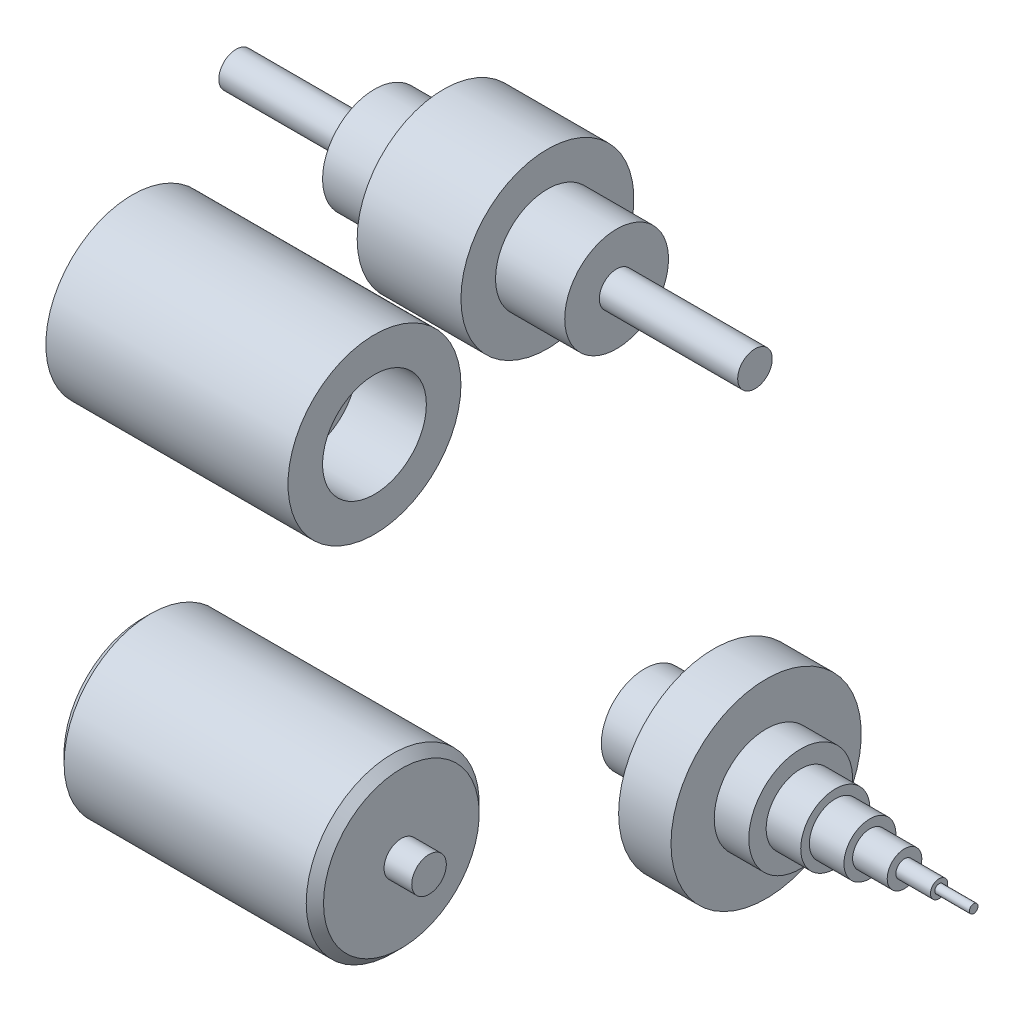
from build123d import *

# Parameters (mm, degrees)
CROQUIS5_R            = 20
CORTAR_EXTRUIR1_DEPTH = 43
CHAFL_N1_SIZE         = 5
CHAFL_N2_SIZE         = 5


with BuildPart() as part:
    # Croquis2 → Revoluci_n2 (revolve)
    with BuildSketch(Plane.XY):
        Polygon((-16.117690813, -67.997629677), (283.882309187, -67.997629677), (283.882309187, -57.997629677), (203.882309187, -57.997629677), (203.882309187, -37.997629677), (163.882309187, -37.997629677), (163.882309187, -17.997629677), (103.882309187, -17.997629677), (103.882309187, -37.997629677), (63.882309187, -37.997629677), (63.882309187, -57.997629677), (-16.117690813, -57.997629677), align=None)
    revolve(axis=Axis((-83.796377596, -67.997629677, 0), (1, 0, 0)))


with BuildPart() as body_2:
    # Croquis2_13 → Revoluci_n4 (revolve)
    with BuildSketch(Plane.XY):
        Polygon((-56.117690813, -220.867194058), (-56.117690813, -210.867194058), (-76.117690813, -210.867194058), (-76.117690813, -260.867194058), (63.882309187, -260.867194058), (63.882309187, -240.867194058), (23.882309187, -240.867194058), (23.882309187, -220.867194058), align=None)
    revolve(axis=Axis((101.470830931, -210.867194058, 0), (-1, 0, 0)))


with BuildPart() as body_3:
    # Croquis3 → Revoluci_n5 (revolve)
    with BuildSketch(Plane.XY):
        Polygon((410.329396223, -275.079193053), (410.329396223, -277.579193053), (390.329396223, -277.579193053), (390.329396223, -280.079193053), (370.329396223, -280.079193053), (370.329396223, -285.079193053), (350.329396223, -285.079193053), (350.329396223, -290.079193053), (330.329396223, -290.079193053), (330.329396223, -295.079193053), (310.329396223, -295.079193053), (310.329396223, -305.079193053), (290.329396223, -305.079193053), (290.329396223, -330.079193053), (260.048278244, -330.079193053), (260.048278244, -300.079193053), (220.048278244, -300.079193053), (220.048278244, -275.079193053), align=None)
    revolve(axis=Axis((141.076094876, -275.079193053, 0), (1, 0, 0)))

    # Croquis5 → Cortar-Extruir1 (cut)
    with BuildSketch(Plane.ZY.offset(-220.048278244)):
        with Locations((0, -275.079193053)):
            Circle(CROQUIS5_R)
    extrude(amount=-CORTAR_EXTRUIR1_DEPTH, mode=Mode.SUBTRACT)


with BuildPart() as body_4:
    # Croquis6 → Revoluci_n6 (revolve)
    with BuildSketch(Plane.XY):
        Polygon((-86.571698606, -415.362975234), (-86.571698606, -405.362975234), (-70.571698606, -405.362975234), (-70.571698606, -365.362975234), (79.428301394, -365.362975234), (79.428301394, -405.362975234), (95.428301394, -405.362975234), (95.428301394, -415.362975234), align=None)
    revolve(axis=Axis((-110.390362139, -415.362975234, 0), (1, 0, 0)))

    # Chafl_n1
    chafl_n1_edges = [body_4.edges().sort_by_distance(p)[0] for p in [
        (-70.571698606, -465.362975234, 0),
    ]]
    chamfer(chafl_n1_edges, length=CHAFL_N1_SIZE)

    # Chafl_n2
    chafl_n2_edges = [body_4.edges().sort_by_distance(p)[0] for p in [
        (79.428301394, -465.362975234, 0),
    ]]
    chamfer(chafl_n2_edges, length=CHAFL_N2_SIZE)


solid = Compound([part.part, body_2.part, body_3.part, body_4.part])
